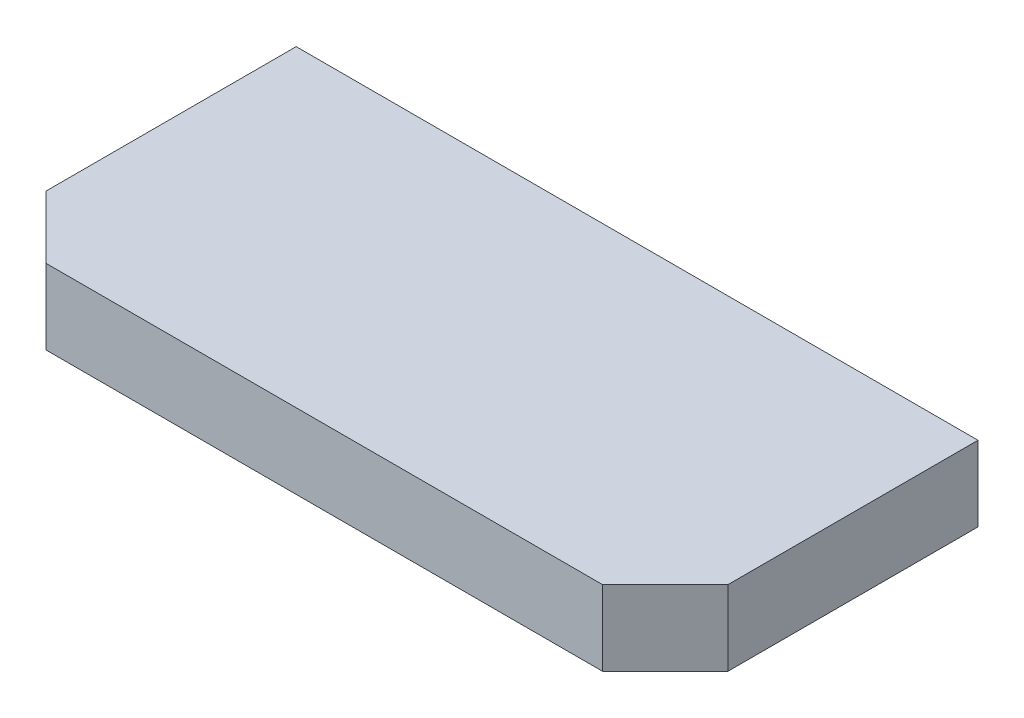
from build123d import *

# Parameters (mm, degrees)
BOSS_EXTRUDE1_DEPTH = 6


with BuildPart() as part:
    # Sketch1 → Boss-Extrude1 (new body)
    with BuildSketch(Plane(origin=(0, 0, 0), x_dir=(1, 0, 0), z_dir=(0, 1, 0))):
        Polygon((-27.25, -7.5), (-22.25, -12.5), (22.25, -12.5), (27.25, -7.5), (27.25, 12.5), (-27.25, 12.5), align=None)
    extrude(amount=BOSS_EXTRUDE1_DEPTH)


solid = part.part
